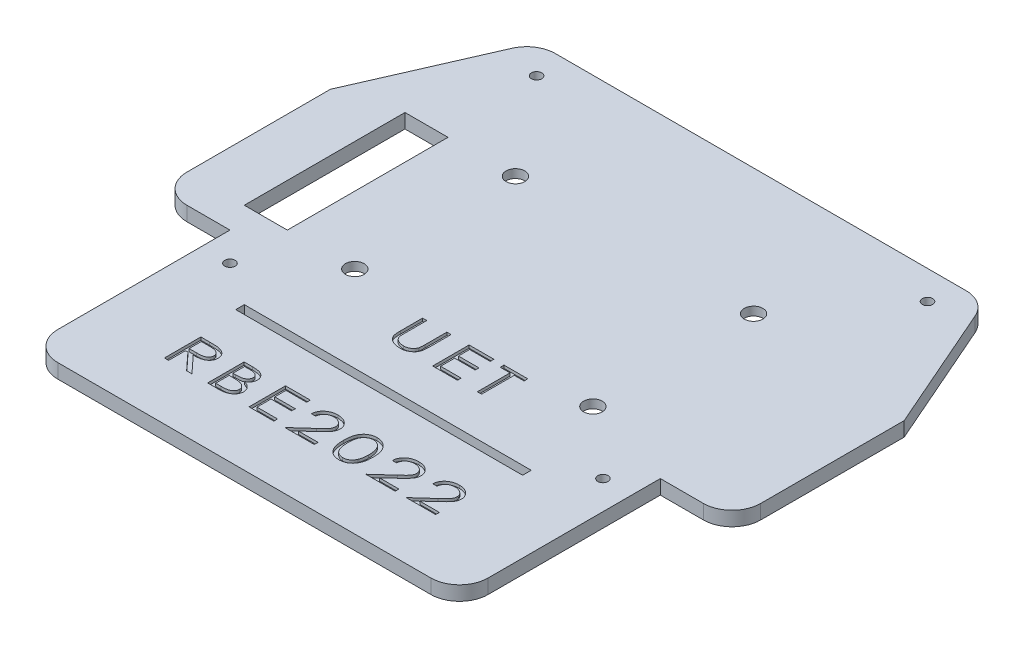
from build123d import *

# Parameters (mm, degrees)
SKETCH1_R           = 1.8
BOSS_EXTRUDE1_DEPTH = 5
SKETCH8_W           = 100
SKETCH8_H           = 3
CUT_EXTRUDE5_DEPTH  = 10
SKETCH9_R           = 1.8
SKETCH9_R_2         = 3.25
SKETCH9_W           = 15
SKETCH9_H           = 56
CUT_EXTRUDE6_DEPTH  = 10
FILLET1_R           = 10
CUT_EXTRUDE7_DEPTH  = 1
SKETCH14_R          = 7.5
CUT_EXTRUDE8_DEPTH  = 2


with BuildPart() as part:
    # Sketch1 → Boss-Extrude1 (new body)
    with BuildSketch(Plane(origin=(0, 0, 0), x_dir=(1, 0, 0), z_dir=(0, 1, 0))):
        with BuildLine():
            Line((-100, -40), (-100, 10))
            Line((-100, 10), (-78.125, 60))
            Line((-78.125, 60), (78.125, 60))
            Line((78.125, 60), (100, 10))
            Line((100, 10), (100, -40))
            ThreePointArc((100, -40), (97.071067812, -47.071067812), (90, -50))
            Line((90, -50), (75, -50))
            Line((75, -50), (75, -60))
            Line((75, -60), (75, -110))
            ThreePointArc((75, -110), (72.071067812, -117.071067812), (65, -120))
            Line((65, -120), (-65, -120))
            ThreePointArc((-65, -120), (-72.071067812, -117.071067812), (-75, -110))
            Line((-75, -110), (-75, -60))
            Line((-75, -60), (-75, -50))
            Line((-75, -50), (-90, -50))
            ThreePointArc((-90, -50), (-97.071067812, -47.071067812), (-100, -40))
        make_face()
        with Locations((-65, -60)):
            Circle(SKETCH1_R, mode=Mode.SUBTRACT)
        with Locations((65, -60)):
            Circle(SKETCH1_R, mode=Mode.SUBTRACT)
    extrude(amount=BOSS_EXTRUDE1_DEPTH)

    # Sketch8 → Cut-Extrude5 (cut)
    with BuildSketch(Plane(origin=(0, 5, 0), x_dir=(1, 0, 0), z_dir=(0, 1, 0))):
        with Locations((0, -71.5)):
            Rectangle(SKETCH8_W, SKETCH8_H)
    extrude(amount=-CUT_EXTRUDE5_DEPTH, mode=Mode.SUBTRACT)

    # Sketch9 → Cut-Extrude6 (cut)
    with BuildSketch(Plane(origin=(0, 5, 0), x_dir=(1, 0, 0), z_dir=(0, 1, 0))):
        with Locations((-68.125, 50)):
            Circle(SKETCH9_R)
        with Locations((68.125, 50)):
            Circle(SKETCH9_R)
        with Locations((41.5, 16)):
            Circle(SKETCH9_R_2)
        with Locations((41.5, -40)):
            Circle(SKETCH9_R_2)
        with Locations((-41.5, 16)):
            Circle(SKETCH9_R_2)
        with Locations((-41.5, -40)):
            Circle(SKETCH9_R_2)
        with Locations((-72.5, -12)):
            Rectangle(SKETCH9_W, SKETCH9_H)
    extrude(amount=-CUT_EXTRUDE6_DEPTH, mode=Mode.SUBTRACT)

    # Fillet1
    fillet1_edges = [part.edges().sort_by_distance(p)[0] for p in [
        (-78.125, 2.5, -60),
        (78.125, 2.5, -60),
    ]]
    fillet(fillet1_edges, radius=FILLET1_R)

    # Sketch13 → Cut-Extrude7 (cut)
    with BuildSketch(Plane(origin=(0, 5, 0), x_dir=(1, 0, 0), z_dir=(0, 1, 0))):
        with BuildLine():
            Line((-14.866348897, -42.992649035), (-13.400964282, -42.992649035))
            Line((-13.400964282, -42.992649035), (-13.400964282, -50.601963939))
            add(Edge.make_bspline(
                [(-13.400964282, -50.601963939), (-13.401628876, -50.709670287), (-13.402890127, -50.9140728), (-13.39446539, -51.204870564), (-13.395620063, -51.463651931), (-13.3851295, -51.690784621), (-13.38113342, -51.886169585), (-13.364699496, -52.049392601), (-13.358810885, -52.181594805), (-13.345597702, -52.258222206), (-13.339906589, -52.29122676)],
                knots=[0, 0, 0, 0, 0.000323097, 0.000613166, 0.000872673, 0.001099224, 0.001295266, 0.001458583, 0.001591265, 0.001691651, 0.001691651, 0.001691651, 0.001691651], degree=3))
            add(Edge.make_bspline(
                [(-13.339906589, -52.29122676), (-13.317284874, -52.410620134), (-13.27312858, -52.643669173), (-13.161183919, -52.974015294), (-13.00876587, -53.273245239), (-12.819053989, -53.546055154), (-12.577198554, -53.788987466), (-12.287320921, -54.012120378), (-11.938597211, -54.208583447), (-11.547195628, -54.385495602), (-11.126186031, -54.530248857), (-10.695723867, -54.637800717), (-10.262824133, -54.704485374), (-9.973483461, -54.711983868), (-9.829089282, -54.715725958)],
                knots=[0, 0, 0, 0, 0.000364255, 0.000711006, 0.001042097, 0.001368899, 0.001703519, 0.002066332, 0.002462987, 0.00290135, 0.003353508, 0.003796535, 0.004231161, 0.004664132, 0.004664132, 0.004664132, 0.004664132], degree=3))
            add(Edge.make_bspline(
                [(-9.829089282, -54.715725958), (-9.705154963, -54.711815781), (-9.458066087, -54.70402003), (-9.09120799, -54.656292888), (-8.733668776, -54.569845422), (-8.385526518, -54.458256027), (-8.058256763, -54.309871321), (-7.751944998, -54.141528398), (-7.479227411, -53.939564662), (-7.230052014, -53.719140631), (-7.011514221, -53.469933571), (-6.826856056, -53.194810511), (-6.67054301, -52.895413871), (-6.59395696, -52.682355156), (-6.554870532, -52.573618586)],
                knots=[0, 0, 0, 0, 0.000371861, 0.000741382, 0.001107313, 0.001474171, 0.001836324, 0.002183755, 0.002520621, 0.002852112, 0.003180229, 0.003511866, 0.003844119, 0.00419043, 0.00419043, 0.00419043, 0.00419043], degree=3))
            add(Edge.make_bspline(
                [(-6.554870532, -52.573618586), (-6.542477438, -52.528804962), (-6.514876532, -52.428999639), (-6.482076366, -52.260860454), (-6.459617766, -52.060781103), (-6.43448333, -51.830372758), (-6.422043294, -51.567910285), (-6.40820902, -51.273722001), (-6.401078027, -50.947990183), (-6.400161143, -50.720689156), (-6.39968223, -50.601963939)],
                knots=[0, 0, 0, 0, 0.000139461, 0.000310595, 0.000513181, 0.000743289, 0.001005773, 0.001301159, 0.001626889, 0.001983068, 0.001983068, 0.001983068, 0.001983068], degree=3))
            Line((-6.39968223, -50.601963939), (-6.39968223, -42.992649035))
            Line((-6.39968223, -42.992649035), (-4.934297615, -42.992649035))
            Line((-4.934297615, -42.992649035), (-4.934297615, -50.663021631))
            add(Edge.make_bspline(
                [(-4.934297615, -50.663021631), (-4.934720257, -50.801284644), (-4.935545304, -51.071189848), (-4.958106139, -51.466447106), (-4.986869456, -51.841670027), (-5.029896975, -52.196558091), (-5.086595167, -52.529834856), (-5.150919413, -52.844817462), (-5.233082128, -53.138103451), (-5.32406431, -53.414540953), (-5.434488183, -53.675907157), (-5.570363396, -53.926035336), (-5.730732685, -54.167597144), (-5.916522619, -54.400504113), (-6.123327838, -54.627521172), (-6.361055907, -54.840119016), (-6.617098072, -55.050118088), (-6.898082999, -55.247258135), (-7.19953783, -55.427466125), (-7.518631399, -55.585409455), (-7.851807462, -55.720278429), (-8.201122296, -55.83129104), (-8.566663088, -55.913033453), (-8.947093682, -55.975127375), (-9.34249932, -56.010529653), (-9.611079473, -56.015673769), (-9.747679025, -56.018290061)],
                knots=[0, 0, 0, 0, 0.000414715, 0.000809571, 0.001187329, 0.001543589, 0.00188153, 0.002201365, 0.0025075, 0.00279471, 0.003073979, 0.003357423, 0.003647425, 0.003942636, 0.00425051, 0.004567449, 0.004898422, 0.005243564, 0.005596099, 0.005951076, 0.006310592, 0.006673468, 0.007049311, 0.007433263, 0.0078292, 0.008238992, 0.008238992, 0.008238992, 0.008238992], degree=3))
            add(Edge.make_bspline(
                [(-9.747679025, -56.018290061), (-9.896126131, -56.015408889), (-10.188295587, -56.009738248), (-10.618469226, -55.978083079), (-11.031641891, -55.917634584), (-11.430164355, -55.841099426), (-11.810960251, -55.73520377), (-12.177632908, -55.61186196), (-12.525278509, -55.46067403), (-12.856580577, -55.290998862), (-13.16546653, -55.101462223), (-13.449398054, -54.894478386), (-13.707601038, -54.67276988), (-13.939112651, -54.436183499), (-14.145841939, -54.185680679), (-14.319889874, -53.917008532), (-14.473136812, -53.636321099), (-14.551989745, -53.438652141), (-14.591589282, -53.339383811)],
                knots=[0, 0, 0, 0, 0.000445394, 0.000876612, 0.001292885, 0.00169752, 0.002093129, 0.002477696, 0.002857181, 0.00322925, 0.003593586, 0.003943171, 0.004282306, 0.004613329, 0.004935171, 0.005254814, 0.005572375, 0.005892736, 0.005892736, 0.005892736, 0.005892736], degree=3))
            add(Edge.make_bspline(
                [(-14.591589282, -53.339383811), (-14.613873956, -53.271847611), (-14.662085528, -53.125737047), (-14.715383729, -52.882744287), (-14.763996159, -52.60361188), (-14.80040216, -52.286662126), (-14.831430285, -51.933820216), (-14.850245701, -51.543431221), (-14.863255994, -51.115954405), (-14.865289097, -50.818221463), (-14.866348897, -50.663021631)],
                knots=[0, 0, 0, 0, 0.000213232, 0.000461315, 0.000745306, 0.001063071, 0.001418012, 0.001807787, 0.00223538, 0.002700972, 0.002700972, 0.002700972, 0.002700972], degree=3))
            Line((-14.866348897, -50.663021631), (-14.866348897, -42.992649035))
        make_face()
        Polygon((1.35057418, -42.992649035), (9.980061359, -42.992649035), (9.980061359, -44.295213138), (2.815958795, -44.295213138), (2.815958795, -48.202905445), (9.980061359, -48.202905445), (9.980061359, -49.505469548), (2.815958795, -49.505469548), (2.815958795, -54.390084933), (9.980061359, -54.390084933), (9.980061359, -55.692649035), (1.35057418, -55.692649035), align=None)
        Polygon((13.496984436, -44.295213138), (13.496984436, -42.992649035), (21.80083059, -42.992649035), (21.80083059, -44.295213138), (18.381599821, -44.295213138), (18.381599821, -55.692649035), (16.916215206, -55.692649035), (16.916215206, -44.295213138), align=None)
        with BuildLine():
            Line((-47.821220692, -87.325982368), (-44.814129346, -87.325982368))
            add(Edge.make_bspline(
                [(-44.814129346, -87.325982368), (-44.613148822, -87.326546908), (-44.227284279, -87.327630773), (-43.674267406, -87.333676757), (-43.17147379, -87.351030176), (-42.720051725, -87.365777026), (-42.319084896, -87.39331751), (-41.969248924, -87.418626255), (-41.669574925, -87.453555079), (-41.488076563, -87.484724814), (-41.405074858, -87.498979163)],
                knots=[0, 0, 0, 0, 0.00060295, 0.00115761, 0.001659024, 0.002112219, 0.002512447, 0.002864643, 0.003164422, 0.003417042, 0.003417042, 0.003417042, 0.003417042], degree=3))
            add(Edge.make_bspline(
                [(-41.405074858, -87.498979163), (-41.295277221, -87.521926355), (-41.078816757, -87.567165579), (-40.766259335, -87.662254546), (-40.469149964, -87.775217328), (-40.186220723, -87.903257973), (-39.920947674, -88.054947147), (-39.670835124, -88.223134419), (-39.435023965, -88.409229887), (-39.21872114, -88.614891625), (-39.017793281, -88.831792946), (-38.848639522, -89.067594534), (-38.701115492, -89.312309954), (-38.584239738, -89.571516369), (-38.492492955, -89.841691015), (-38.426176999, -90.124456124), (-38.384087704, -90.419149044), (-38.379801306, -90.620410542), (-38.377630948, -90.722316503)],
                knots=[0, 0, 0, 0, 0.000336376, 0.000663148, 0.000978777, 0.001289549, 0.001593744, 0.001894332, 0.002193117, 0.002493673, 0.002789048, 0.003078592, 0.003362629, 0.003644975, 0.003929774, 0.004217333, 0.004515239, 0.004820793, 0.004820793, 0.004820793, 0.004820793], degree=3))
            add(Edge.make_bspline(
                [(-38.377630948, -90.722316503), (-38.380011882, -90.808012846), (-38.384713207, -90.977226402), (-38.409249154, -91.227617107), (-38.455644485, -91.469033214), (-38.519145967, -91.703407723), (-38.603697465, -91.928128347), (-38.703278834, -92.147505434), (-38.822745594, -92.357562093), (-38.960284948, -92.559525984), (-39.116507523, -92.748936491), (-39.283819007, -92.931855652), (-39.470658294, -93.098904033), (-39.672227661, -93.255755074), (-39.891954196, -93.396184059), (-40.124009822, -93.530737475), (-40.373827228, -93.649067068), (-40.640183136, -93.757277418), (-40.927863172, -93.850776105), (-41.238030441, -93.93601622), (-41.575205513, -94.002257666), (-41.937285594, -94.061824743), (-42.326166706, -94.106576923), (-42.741111543, -94.139247835), (-43.181479902, -94.15980799), (-43.483557675, -94.162870403), (-43.638768769, -94.164443907)],
                knots=[0, 0, 0, 0, 0.000257153, 0.000507766, 0.000753753, 0.000993841, 0.001235327, 0.001473248, 0.00171591, 0.001959358, 0.002205305, 0.002451923, 0.002702291, 0.002956214, 0.003217301, 0.003483943, 0.003760452, 0.004045797, 0.004345878, 0.004667409, 0.005010179, 0.005376146, 0.005768073, 0.006184073, 0.006624668, 0.007090295, 0.007090295, 0.007090295, 0.007090295], degree=3))
            Line((-43.638768769, -94.164443907), (-38.214810435, -100.025982368))
            Line((-38.214810435, -100.025982368), (-40.07198191, -100.025982368))
            Line((-40.07198191, -100.025982368), (-45.495940243, -94.164443907))
            Line((-45.495940243, -94.164443907), (-46.355836076, -94.164443907))
            Line((-46.355836076, -94.164443907), (-46.355836076, -100.025982368))
            Line((-46.355836076, -100.025982368), (-47.821220692, -100.025982368))
            Line((-47.821220692, -100.025982368), (-47.821220692, -87.325982368))
        make_face()
        with BuildLine():
            Line((-46.355836076, -88.628546471), (-46.355836076, -92.861879804))
            Line((-46.355836076, -92.861879804), (-43.697282391, -92.879688298))
            add(Edge.make_bspline(
                [(-43.697282391, -92.879688298), (-43.57260519, -92.879747875), (-43.331657561, -92.879863012), (-42.98312247, -92.865307602), (-42.659823714, -92.848935678), (-42.361970593, -92.823688851), (-42.088701854, -92.790775214), (-41.840619214, -92.75117285), (-41.617224186, -92.702766325), (-41.357112274, -92.630089572), (-41.065989425, -92.516251129), (-40.751890789, -92.344959171), (-40.480532046, -92.135441034), (-40.252004343, -91.89232154), (-40.072051206, -91.623309834), (-39.939252879, -91.336228593), (-39.856804254, -91.033017235), (-39.847629262, -90.824584211), (-39.843015564, -90.719772433)],
                knots=[0, 0, 0, 0, 0.000373987, 0.000722757, 0.001046344, 0.001345086, 0.001619303, 0.001871923, 0.002098474, 0.002304653, 0.002681657, 0.00303353, 0.003374474, 0.003705653, 0.004030229, 0.004341001, 0.004651388, 0.004965341, 0.004965341, 0.004965341, 0.004965341], degree=3))
            add(Edge.make_bspline(
                [(-39.843015564, -90.719772433), (-39.847642214, -90.617493529), (-39.856845146, -90.414049217), (-39.939492161, -90.11724107), (-40.074102231, -89.83652963), (-40.25899338, -89.57530145), (-40.483016147, -89.337168164), (-40.746574899, -89.134392044), (-41.041833731, -88.96784023), (-41.315611931, -88.86100467), (-41.559870887, -88.795606895), (-41.772720715, -88.749085965), (-42.014078275, -88.71199819), (-42.284119702, -88.682617056), (-42.581782251, -88.656632147), (-42.90844753, -88.639514797), (-43.263026545, -88.629317847), (-43.509013673, -88.628809408), (-43.636224698, -88.628546471)],
                knots=[0, 0, 0, 0, 0.000306347, 0.000609358, 0.000916601, 0.001236315, 0.001565642, 0.001893867, 0.002229935, 0.002579538, 0.002772099, 0.002988166, 0.003232847, 0.003504241, 0.003802982, 0.00412911, 0.004485425, 0.004867044, 0.004867044, 0.004867044, 0.004867044], degree=3))
            Line((-43.636224698, -88.628546471), (-46.355836076, -88.628546471))
        make_face(mode=Mode.SUBTRACT)
        with BuildLine():
            Line((-32.744041205, -87.325982368), (-29.770022775, -87.325982368))
            add(Edge.make_bspline(
                [(-29.770022775, -87.325982368), (-29.62498642, -87.326646769), (-29.342428397, -87.327941146), (-28.931869749, -87.34690843), (-28.547283973, -87.373096479), (-28.189317822, -87.414712247), (-27.857318908, -87.46457365), (-27.550435031, -87.524922095), (-27.26971284, -87.597977555), (-26.935035666, -87.712284205), (-26.554370754, -87.882295616), (-26.141946239, -88.136157662), (-25.784114115, -88.443473896), (-25.480533333, -88.795684406), (-25.236658761, -89.180605749), (-25.056463343, -89.591450823), (-24.949533739, -90.02576471), (-24.93565068, -90.323169316), (-24.928656589, -90.472997593)],
                knots=[0, 0, 0, 0, 0.000435066, 0.00084759, 0.001232762, 0.001591251, 0.001928386, 0.00223972, 0.00252913, 0.002797839, 0.003300002, 0.003776511, 0.004245615, 0.004709201, 0.005166568, 0.005607522, 0.006049942, 0.006499113, 0.006499113, 0.006499113, 0.006499113], degree=3))
            add(Edge.make_bspline(
                [(-24.928656589, -90.472997593), (-24.933331805, -90.613461612), (-24.942554666, -90.89055686), (-25.037358665, -91.294544977), (-25.181460234, -91.680833023), (-25.389811823, -92.04313643), (-25.654459112, -92.378254169), (-25.972576727, -92.683606515), (-26.348908511, -92.953183074), (-26.628651855, -93.099331378), (-26.773107711, -93.174800477)],
                knots=[0, 0, 0, 0, 0.000420703, 0.000829927, 0.001238161, 0.001654061, 0.002078013, 0.002515245, 0.002972761, 0.003461282, 0.003461282, 0.003461282, 0.003461282], degree=3))
            add(Edge.make_bspline(
                [(-26.773107711, -93.174800477), (-26.597613362, -93.230117089), (-26.263179884, -93.335532033), (-25.800054682, -93.521814256), (-25.401205008, -93.725813092), (-25.061447849, -93.945679591), (-24.774881073, -94.1894538), (-24.518071761, -94.445676476), (-24.303309415, -94.733197992), (-24.118462343, -95.039301799), (-23.970705776, -95.363291192), (-23.865666309, -95.704360283), (-23.799819438, -96.05806919), (-23.792565423, -96.299482136), (-23.788913, -96.421034452)],
                knots=[0, 0, 0, 0, 0.000551893, 0.001051724, 0.00149548, 0.001894153, 0.00226256, 0.002622364, 0.002980066, 0.003336091, 0.003693603, 0.004045247, 0.004404546, 0.004768917, 0.004768917, 0.004768917, 0.004768917], degree=3))
            add(Edge.make_bspline(
                [(-23.788913, -96.421034452), (-23.792766171, -96.545081917), (-23.800362449, -96.789633413), (-23.862439454, -97.14897849), (-23.96845806, -97.491407551), (-24.111287625, -97.821364377), (-24.299931687, -98.134911057), (-24.526020905, -98.437437506), (-24.800115902, -98.7185635), (-25.105105648, -98.988925249), (-25.448823581, -99.231126849), (-25.820550199, -99.446921526), (-26.222884363, -99.623144813), (-26.650892265, -99.773092954), (-27.108581945, -99.885811137), (-27.594325351, -99.965812439), (-28.106708895, -100.019212996), (-28.45798997, -100.023689542), (-28.637911397, -100.025982368)],
                knots=[0, 0, 0, 0, 0.000371991, 0.000733357, 0.001089863, 0.001445305, 0.001809187, 0.002185202, 0.002575674, 0.002984921, 0.003406355, 0.003834878, 0.004272199, 0.004721953, 0.005193979, 0.00568416, 0.006198043, 0.006737602, 0.006737602, 0.006737602, 0.006737602], degree=3))
            Line((-28.637911397, -100.025982368), (-32.744041205, -100.025982368))
            Line((-32.744041205, -100.025982368), (-32.744041205, -87.325982368))
        make_face()
        with BuildLine():
            Line((-31.278656589, -88.628546471), (-31.278656589, -92.699059292))
            Line((-31.278656589, -92.699059292), (-30.395864121, -92.699059292))
            add(Edge.make_bspline(
                [(-30.395864121, -92.699059292), (-30.266118449, -92.697608113), (-30.01591775, -92.69480967), (-29.654399163, -92.68681966), (-29.319546302, -92.664278936), (-29.011176005, -92.64172409), (-28.728672049, -92.605221302), (-28.473456639, -92.561878751), (-28.243094564, -92.516128682), (-27.978252764, -92.437300174), (-27.677987035, -92.323207454), (-27.355922368, -92.143887772), (-27.071355744, -91.931751811), (-26.832504579, -91.684090175), (-26.637385832, -91.412339658), (-26.495810751, -91.121107482), (-26.410053412, -90.812778012), (-26.39942467, -90.602433751), (-26.394041205, -90.495894227)],
                knots=[0, 0, 0, 0, 0.000389276, 0.000750677, 0.001084571, 0.001395989, 0.001678094, 0.00193866, 0.002172673, 0.002381999, 0.002767037, 0.003133736, 0.003484311, 0.003827949, 0.004161843, 0.004483856, 0.004794899, 0.005114137, 0.005114137, 0.005114137, 0.005114137], degree=3))
            add(Edge.make_bspline(
                [(-26.394041205, -90.495894227), (-26.396885589, -90.425408037), (-26.402468725, -90.287053327), (-26.434494833, -90.084717858), (-26.494506739, -89.894483975), (-26.575753292, -89.715393273), (-26.681084735, -89.548511788), (-26.810407575, -89.394794152), (-26.961031859, -89.251725999), (-27.136050324, -89.121175665), (-27.336057023, -89.003523113), (-27.563642959, -88.901422359), (-27.819662908, -88.820207564), (-28.101007837, -88.74663918), (-28.411339987, -88.696850697), (-28.747156477, -88.654534541), (-29.110822859, -88.63275495), (-29.362100582, -88.629985881), (-29.492719089, -88.628546471)],
                knots=[0, 0, 0, 0, 0.000211541, 0.000415225, 0.00061237, 0.000808181, 0.001003694, 0.001202392, 0.00140934, 0.001625586, 0.001855961, 0.0021042, 0.002372102, 0.002660873, 0.002975815, 0.00331409, 0.003676073, 0.004067934, 0.004067934, 0.004067934, 0.004067934], degree=3))
            Line((-29.492719089, -88.628546471), (-31.278656589, -88.628546471))
        make_face(mode=Mode.SUBTRACT)
        with BuildLine():
            Line((-31.278656589, -94.001623394), (-31.278656589, -98.723418266))
            Line((-31.278656589, -98.723418266), (-29.401132551, -98.723418266))
            add(Edge.make_bspline(
                [(-29.401132551, -98.723418266), (-29.267140874, -98.72203129), (-29.008449902, -98.719353527), (-28.634298309, -98.710480428), (-28.288000888, -98.690963167), (-27.97017333, -98.658886641), (-27.679383869, -98.625817723), (-27.416478643, -98.579022638), (-27.180751168, -98.527436953), (-26.907112567, -98.446258605), (-26.599529747, -98.322303912), (-26.267959628, -98.131307094), (-25.971391459, -97.907719851), (-25.720876801, -97.644694543), (-25.514733777, -97.360622854), (-25.362944876, -97.059050524), (-25.273178926, -96.74328523), (-25.260590076, -96.528429039), (-25.254297615, -96.421034452)],
                knots=[0, 0, 0, 0, 0.000401995, 0.000776112, 0.001122704, 0.001442175, 0.001734378, 0.002000388, 0.002242944, 0.002457869, 0.002856127, 0.003234476, 0.003602875, 0.00396633, 0.004320038, 0.004652261, 0.004974465, 0.005296468, 0.005296468, 0.005296468, 0.005296468], degree=3))
            add(Edge.make_bspline(
                [(-25.254297615, -96.421034452), (-25.256257797, -96.353936628), (-25.260149123, -96.220734918), (-25.291133495, -96.024339539), (-25.343628248, -95.835047015), (-25.409815899, -95.650502581), (-25.505831076, -95.476868813), (-25.613159409, -95.304617231), (-25.747259701, -95.143099618), (-25.897723611, -94.9873876), (-26.064803981, -94.84032379), (-26.248723668, -94.705064169), (-26.448638875, -94.583244549), (-26.662285042, -94.470766133), (-26.892057411, -94.371719331), (-27.136198297, -94.285834161), (-27.395372861, -94.211299305), (-27.574247368, -94.171933065), (-27.666076461, -94.151723554)],
                knots=[0, 0, 0, 0, 0.000201239, 0.000399497, 0.000594513, 0.000790142, 0.000985887, 0.001188424, 0.001398213, 0.001614115, 0.001837646, 0.002065095, 0.002298096, 0.002539341, 0.00278888, 0.003047976, 0.003315309, 0.003597334, 0.003597334, 0.003597334, 0.003597334], degree=3))
            add(Edge.make_bspline(
                [(-27.666076461, -94.151723554), (-27.738062364, -94.139205281), (-27.893381578, -94.112195431), (-28.145657669, -94.083228059), (-28.433231428, -94.057740578), (-28.757381858, -94.038831378), (-29.11769953, -94.01934799), (-29.514754442, -94.011670721), (-29.948067678, -94.002605662), (-30.249149309, -94.001959897), (-30.406040403, -94.001623394)],
                knots=[0, 0, 0, 0, 0.00021916, 0.000472866, 0.000761469, 0.001085207, 0.001446903, 0.001843909, 0.002276468, 0.002747128, 0.002747128, 0.002747128, 0.002747128], degree=3))
            Line((-30.406040403, -94.001623394), (-31.278656589, -94.001623394))
        make_face(mode=Mode.SUBTRACT)
        Polygon((-18.318143769, -87.325982368), (-9.688656589, -87.325982368), (-9.688656589, -88.628546471), (-16.852759153, -88.628546471), (-16.852759153, -92.536238779), (-9.688656589, -92.536238779), (-9.688656589, -93.838802881), (-16.852759153, -93.838802881), (-16.852759153, -98.723418266), (-9.688656589, -98.723418266), (-9.688656589, -100.025982368), (-18.318143769, -100.025982368), align=None)
        with BuildLine():
            Line((-3.892246333, -91.233674676), (-5.357630948, -91.233674676))
            add(Edge.make_bspline(
                [(-5.357630948, -91.233674676), (-5.348976591, -91.082388777), (-5.331946404, -90.78468589), (-5.251515195, -90.350432525), (-5.128649065, -89.93683372), (-4.963291454, -89.54417044), (-4.754176322, -89.172647247), (-4.507854568, -88.81850146), (-4.211674294, -88.490727001), (-3.879812039, -88.183817705), (-3.51635588, -87.907083316), (-3.129982872, -87.662381873), (-2.720158735, -87.458876872), (-2.29034042, -87.290681094), (-1.839554252, -87.161107452), (-1.369223358, -87.066613419), (-0.877237863, -87.009640674), (-0.541857548, -87.003476831), (-0.371252743, -87.000341343)],
                knots=[0, 0, 0, 0, 0.000454243, 0.000893867, 0.001321278, 0.001746534, 0.00216908, 0.002598214, 0.003037875, 0.003491562, 0.003952565, 0.004406423, 0.004861521, 0.005323092, 0.005789269, 0.006266748, 0.006760933, 0.007272601, 0.007272601, 0.007272601, 0.007272601], degree=3))
            add(Edge.make_bspline(
                [(-0.371252743, -87.000341343), (-0.20320962, -87.003668385), (0.126124652, -87.010188788), (0.607051221, -87.063865635), (1.063429729, -87.154301346), (1.496700425, -87.273418802), (1.904166343, -87.435955662), (2.286366894, -87.632255631), (2.646355166, -87.861379954), (2.973463016, -88.129162739), (3.272194297, -88.416034355), (3.533838659, -88.719632529), (3.75356538, -89.037361954), (3.937293483, -89.365735451), (4.073358831, -89.710713645), (4.177919494, -90.065054952), (4.236483497, -90.434591695), (4.244649435, -90.684811716), (4.248779308, -90.811358971)],
                knots=[0, 0, 0, 0, 0.000504041, 0.000987829, 0.001449345, 0.001898746, 0.002333849, 0.002762802, 0.00318622, 0.003611354, 0.004028767, 0.004427505, 0.004811416, 0.005186025, 0.005553571, 0.005921547, 0.006292537, 0.00667215, 0.00667215, 0.00667215, 0.00667215], degree=3))
            add(Edge.make_bspline(
                [(4.248779308, -90.811358971), (4.246572408, -90.900459109), (4.242169027, -91.078238756), (4.21442609, -91.342968199), (4.164511561, -91.603487659), (4.100513483, -91.861492327), (4.008810875, -92.112366037), (3.905127463, -92.361505743), (3.780299967, -92.605722412), (3.631714606, -92.848678932), (3.457028894, -93.101140779), (3.247823838, -93.369348339), (3.003038537, -93.659232924), (2.722455068, -93.969204642), (2.406657085, -94.300678069), (2.05162682, -94.650508072), (1.663441171, -95.024846979), (1.388923573, -95.277611065), (1.246776103, -95.408494388)],
                knots=[0, 0, 0, 0, 0.000267321, 0.00053338, 0.000797339, 0.001062668, 0.001329807, 0.001597721, 0.001871926, 0.0021516, 0.00245152, 0.002792464, 0.003171624, 0.003589534, 0.004046589, 0.004544896, 0.005084683, 0.00566434, 0.00566434, 0.00566434, 0.00566434], degree=3))
            Line((1.246776103, -95.408494388), (-2.409053224, -98.723418266))
            Line((-2.409053224, -98.723418266), (4.411599821, -98.723418266))
            Line((4.411599821, -98.723418266), (4.411599821, -100.025982368))
            Line((4.411599821, -100.025982368), (-5.846092487, -100.025982368))
            Line((-5.846092487, -100.025982368), (-0.045611717, -94.769932689))
            add(Edge.make_bspline(
                [(-0.045611717, -94.769932689), (0.095427774, -94.644727586), (0.366195784, -94.404358478), (0.750695846, -94.054454814), (1.094097719, -93.72691839), (1.403620628, -93.429138775), (1.669182547, -93.150999225), (1.900801084, -92.902177837), (2.091478594, -92.676078741), (2.293901699, -92.413207741), (2.488876053, -92.091247625), (2.659894396, -91.697594169), (2.764518256, -91.290786946), (2.777092862, -91.015477566), (2.783394693, -90.877504804)],
                knots=[0, 0, 0, 0, 0.000565791, 0.001086208, 0.001559494, 0.001989472, 0.00237451, 0.002713015, 0.003009112, 0.003261488, 0.003707833, 0.004134085, 0.004545643, 0.004959107, 0.004959107, 0.004959107, 0.004959107], degree=3))
            add(Edge.make_bspline(
                [(2.783394693, -90.877504804), (2.780303882, -90.790839931), (2.774204321, -90.619811116), (2.730408603, -90.368238348), (2.655109275, -90.127121721), (2.552948048, -89.893518964), (2.420311656, -89.669908499), (2.257471176, -89.456275794), (2.065052732, -89.25341001), (1.848765567, -89.05814784), (1.608640305, -88.883449682), (1.355994905, -88.725273273), (1.087281885, -88.596437448), (0.806492095, -88.489228398), (0.513107427, -88.404431464), (0.205513284, -88.346930056), (-0.114276993, -88.310532107), (-0.332144642, -88.305469482), (-0.442486717, -88.302905445)],
                knots=[0, 0, 0, 0, 0.000259944, 0.000512986, 0.000763251, 0.00101614, 0.001276183, 0.001541279, 0.001820259, 0.002113931, 0.002414142, 0.002709977, 0.003006947, 0.0033065, 0.003610876, 0.003921721, 0.004244247, 0.00457522, 0.00457522, 0.00457522, 0.00457522], degree=3))
            add(Edge.make_bspline(
                [(-0.442486717, -88.302905445), (-0.5587438, -88.305542136), (-0.787568315, -88.310731835), (-1.123000609, -88.345795432), (-1.443399049, -88.40791686), (-1.748403154, -88.490783958), (-2.038899409, -88.598563243), (-2.314469933, -88.730669172), (-2.574376839, -88.889487148), (-2.818305416, -89.069486855), (-3.042885693, -89.270052065), (-3.243037558, -89.491806801), (-3.413007249, -89.736261744), (-3.562469524, -89.996729341), (-3.684622704, -90.278459873), (-3.780523523, -90.579452732), (-3.853219802, -90.899485107), (-3.879036876, -91.120560273), (-3.892246333, -91.233674676)],
                knots=[0, 0, 0, 0, 0.00034877, 0.000686471, 0.001010288, 0.00132691, 0.001633605, 0.001938554, 0.002242227, 0.002545996, 0.002846853, 0.003144117, 0.003439865, 0.003738379, 0.00404371, 0.004359092, 0.004684982, 0.005026428, 0.005026428, 0.005026428, 0.005026428], degree=3))
        make_face()
        with BuildLine():
            add(Edge.make_bspline(
                [(8.254163924, -93.68107051), (8.255890875, -93.477494038), (8.259246102, -93.081973001), (8.291642755, -92.505925214), (8.336611395, -91.964748668), (8.409410606, -91.459979025), (8.49659306, -90.9907007), (8.60566026, -90.557171405), (8.734428978, -90.158803648), (8.885830325, -89.794579937), (9.056012938, -89.459446203), (9.237786327, -89.145013964), (9.44103051, -88.853662879), (9.658404075, -88.581465605), (9.894148118, -88.33159227), (10.14312348, -88.100484609), (10.412743509, -87.895352358), (10.693604295, -87.706186801), (10.989933714, -87.541746425), (11.294580594, -87.396267255), (11.60833501, -87.273757798), (11.930844811, -87.174654332), (12.261216652, -87.095247656), (12.600461858, -87.039756182), (12.94810442, -87.00542549), (13.182796145, -87.002050037), (13.301599821, -87.000341343)],
                knots=[0, 0, 0, 0, 0.000610662, 0.001186432, 0.00173047, 0.002239208, 0.00271571, 0.003161823, 0.003579369, 0.003970569, 0.00434375, 0.00470634, 0.005059197, 0.005408439, 0.005750406, 0.006088911, 0.006426286, 0.006765679, 0.007103963, 0.007441942, 0.007777846, 0.008113403, 0.008453405, 0.008796365, 0.009143935, 0.009500251, 0.009500251, 0.009500251, 0.009500251], degree=3))
            add(Edge.make_bspline(
                [(13.301599821, -87.000341343), (13.422098426, -87.002050796), (13.660173124, -87.005428244), (14.012890866, -87.039759631), (14.357214533, -87.095240103), (14.692654454, -87.174668382), (15.020280775, -87.273682094), (15.338964581, -87.396440495), (15.649639907, -87.541104448), (15.949239079, -87.709470327), (16.238991225, -87.897737107), (16.5124943, -88.111090221), (16.770146638, -88.34665982), (17.014193974, -88.601979046), (17.239126173, -88.882614908), (17.45156739, -89.183741811), (17.647264921, -89.507952182), (17.828559686, -89.854898238), (17.993040995, -90.227795397), (18.132294401, -90.631309307), (18.248392562, -91.065232145), (18.344418607, -91.529087512), (18.421307577, -92.023998458), (18.472400065, -92.549804191), (18.507208147, -93.105641055), (18.510280271, -93.485967768), (18.511856231, -93.68107051)],
                knots=[0, 0, 0, 0, 0.000361401, 0.000714037, 0.001062018, 0.001406971, 0.001747392, 0.002088041, 0.002430623, 0.00277459, 0.003118228, 0.003466311, 0.003813881, 0.004164788, 0.004524763, 0.004891788, 0.005269632, 0.005659938, 0.006065491, 0.006491112, 0.006939158, 0.007412163, 0.007911579, 0.008440905, 0.008996497, 0.009581722, 0.009581722, 0.009581722, 0.009581722], degree=3))
            add(Edge.make_bspline(
                [(18.511856231, -93.68107051), (18.510263141, -93.875323306), (18.507157964, -94.253951609), (18.472597565, -94.807276896), (18.420657789, -95.330309473), (18.346792927, -95.822752084), (18.254369825, -96.284614163), (18.136088921, -96.71573356), (18.001432143, -97.118417039), (17.838628156, -97.48935753), (17.659987602, -97.833794704), (17.466319988, -98.156542203), (17.254502178, -98.4567551), (17.02848839, -98.737176223), (16.786275488, -98.996018445), (16.525231351, -99.229838527), (16.250677794, -99.444511232), (15.960237339, -99.63547894), (15.656965906, -99.801740223), (15.346801576, -99.951971079), (15.024711469, -100.07218458), (14.696466041, -100.175176114), (14.359714411, -100.254199679), (14.014457554, -100.309042854), (13.661170983, -100.347280653), (13.422122334, -100.350167777), (13.301599821, -100.351623394)],
                knots=[0, 0, 0, 0, 0.000582681, 0.001135734, 0.001662529, 0.002159046, 0.002629046, 0.003074636, 0.003499427, 0.003901632, 0.004288506, 0.004662856, 0.005029882, 0.005389857, 0.005742612, 0.006092068, 0.00644015, 0.006787311, 0.007133501, 0.007477167, 0.007820192, 0.008163793, 0.008508746, 0.008856727, 0.009212141, 0.009573543, 0.009573543, 0.009573543, 0.009573543], degree=3))
            add(Edge.make_bspline(
                [(13.301599821, -100.351623394), (13.182797864, -100.349905277), (12.948109536, -100.346511209), (12.600442089, -100.312316903), (12.262296386, -100.256484171), (11.932798572, -100.179333725), (11.611016839, -100.084523761), (11.300328532, -99.960065365), (10.997496606, -99.818113723), (10.70387541, -99.655863153), (10.424325747, -99.468874937), (10.15616876, -99.263885823), (9.905729998, -99.034073241), (9.675688982, -98.779842215), (9.454262441, -98.510891752), (9.253637441, -98.216140493), (9.06851872, -97.900349214), (8.896012612, -97.562491635), (8.742232476, -97.195738885), (8.609888559, -96.795280275), (8.50305049, -96.359103625), (8.41094227, -95.890648178), (8.340265382, -95.387012781), (8.290578741, -94.848771254), (8.259582009, -94.275899383), (8.256002689, -93.882940897), (8.254163924, -93.68107051)],
                knots=[0, 0, 0, 0, 0.000356315, 0.000703886, 0.001046845, 0.001383788, 0.001718602, 0.002052137, 0.002386728, 0.002721551, 0.003057417, 0.003394792, 0.003733297, 0.004075396, 0.004422659, 0.00477761, 0.005143682, 0.005520282, 0.005914809, 0.006335567, 0.006784146, 0.007261131, 0.00776735, 0.008309087, 0.008882317, 0.009487891, 0.009487891, 0.009487891, 0.009487891], degree=3))
        make_face()
        with BuildLine():
            add(Edge.make_bspline(
                [(9.719548539, -93.675982368), (9.721184553, -93.845603109), (9.72435964, -94.174793689), (9.743906015, -94.653441495), (9.77971114, -95.099699517), (9.826608112, -95.514209568), (9.890824707, -95.896019702), (9.96509955, -96.247487832), (10.05677001, -96.566051767), (10.161583933, -96.855404892), (10.282531723, -97.119029451), (10.415607372, -97.364316241), (10.559448978, -97.594743077), (10.721487515, -97.8051194), (10.89200149, -98.003291397), (11.077725345, -98.184641283), (11.279716149, -98.346333686), (11.55928701, -98.542500821), (11.927685713, -98.744302502), (12.38938631, -98.918374784), (12.863966556, -99.028518377), (13.185684342, -99.042188246), (13.34739309, -99.049059292)],
                knots=[0, 0, 0, 0, 0.000508871, 0.000987589, 0.00143676, 0.001851725, 0.002238599, 0.002597881, 0.002928815, 0.003232243, 0.003520274, 0.003798033, 0.004069057, 0.004334153, 0.004593823, 0.004852894, 0.005111552, 0.005369157, 0.005876959, 0.00636648, 0.006846069, 0.007330753, 0.007330753, 0.007330753, 0.007330753], degree=3))
            add(Edge.make_bspline(
                [(13.34739309, -99.049059292), (13.510002806, -99.04339634), (13.832734109, -99.032157087), (14.305423648, -98.920291367), (14.764161444, -98.753269859), (15.12624768, -98.553302314), (15.401937443, -98.363223471), (15.597713486, -98.200628407), (15.780064667, -98.02118133), (15.947757007, -97.822774042), (16.108201603, -97.612116853), (16.248327932, -97.379290404), (16.380122743, -97.132001524), (16.454160776, -96.957602582), (16.491864244, -96.868790862)],
                knots=[0, 0, 0, 0, 0.000487042, 0.000966631, 0.001449603, 0.001948266, 0.00220233, 0.002453472, 0.002710725, 0.002968732, 0.003232298, 0.003504133, 0.003782938, 0.004072247, 0.004072247, 0.004072247, 0.004072247], degree=3))
            add(Edge.make_bspline(
                [(16.491864244, -96.868790862), (16.536579767, -96.755681372), (16.627063188, -96.526800371), (16.737460183, -96.168303268), (16.83439385, -95.795009767), (16.914075576, -95.404573018), (16.970868872, -94.996493437), (17.013680118, -94.571334892), (17.043627231, -94.129251848), (17.045513414, -93.828677432), (17.046471616, -93.675982368)],
                knots=[0, 0, 0, 0, 0.000364762, 0.000738108, 0.001124379, 0.001521531, 0.001932767, 0.002359822, 0.002803374, 0.003261371, 0.003261371, 0.003261371, 0.003261371], degree=3))
            add(Edge.make_bspline(
                [(17.046471616, -93.675982368), (17.045059493, -93.523310182), (17.042296351, -93.224571945), (17.019205474, -92.787485998), (16.981113395, -92.37164791), (16.929229561, -91.976467054), (16.856636961, -91.603468679), (16.774779529, -91.250035824), (16.671412381, -90.919663286), (16.558343388, -90.60781457), (16.428187327, -90.31880786), (16.287655035, -90.049199152), (16.135488479, -89.799557723), (15.969991375, -89.569566743), (15.791423871, -89.360964676), (15.602779434, -89.170909407), (15.401307239, -89.002945345), (15.120988968, -88.807654778), (14.753775643, -88.609698016), (14.298187974, -88.428890963), (13.82610363, -88.324765432), (13.507302557, -88.310207601), (13.34739309, -88.302905445)],
                knots=[0, 0, 0, 0, 0.000457996, 0.000896175, 0.001312611, 0.001710544, 0.002091246, 0.002452227, 0.002798258, 0.003129075, 0.003446799, 0.003748354, 0.00404069, 0.004323128, 0.004597416, 0.004863657, 0.005125548, 0.005383153, 0.005887502, 0.00637318, 0.006849737, 0.007329346, 0.007329346, 0.007329346, 0.007329346], degree=3))
            add(Edge.make_bspline(
                [(13.34739309, -88.302905445), (13.18492813, -88.310132775), (12.861896313, -88.324502995), (12.384128778, -88.429128166), (11.924846024, -88.60770286), (11.559075676, -88.807797181), (11.281549093, -89.000449157), (11.082564942, -89.162172701), (10.899851821, -89.345337879), (10.726088979, -89.539957319), (10.567388132, -89.753067414), (10.423559857, -89.983138971), (10.286914475, -90.227047952), (10.167528409, -90.492130724), (10.058386948, -90.78016821), (9.968391987, -91.098745653), (9.892442425, -91.449824499), (9.830107358, -91.832910153), (9.779000454, -92.247825565), (9.743969606, -92.695152287), (9.72432593, -93.174621181), (9.72117293, -93.505511404), (9.719548539, -93.675982368)],
                knots=[0, 0, 0, 0, 0.000487221, 0.00096875, 0.001459175, 0.001961292, 0.002215356, 0.002472042, 0.002729295, 0.002990642, 0.003254208, 0.003525233, 0.003804212, 0.004092243, 0.004396554, 0.004727489, 0.005084285, 0.005473669, 0.005891463, 0.006338097, 0.006819357, 0.007330772, 0.007330772, 0.007330772, 0.007330772], degree=3))
        make_face(mode=Mode.SUBTRACT)
        with BuildLine():
            Line((24.308266488, -91.233674676), (22.842881872, -91.233674676))
            add(Edge.make_bspline(
                [(22.842881872, -91.233674676), (22.851536229, -91.082388777), (22.868566416, -90.78468589), (22.948997626, -90.350432525), (23.071863755, -89.93683372), (23.237221367, -89.54417044), (23.446336498, -89.172647247), (23.692658252, -88.81850146), (23.988838527, -88.490727001), (24.320700781, -88.183817705), (24.68415694, -87.907083316), (25.070529948, -87.662381873), (25.480354086, -87.458876872), (25.910172401, -87.290681094), (26.360958568, -87.161107452), (26.831289462, -87.066613419), (27.323274958, -87.009640674), (27.658655272, -87.003476831), (27.829260077, -87.000341343)],
                knots=[0, 0, 0, 0, 0.000454243, 0.000893867, 0.001321278, 0.001746534, 0.00216908, 0.002598214, 0.003037875, 0.003491562, 0.003952565, 0.004406423, 0.004861521, 0.005323092, 0.005789269, 0.006266748, 0.006760933, 0.007272601, 0.007272601, 0.007272601, 0.007272601], degree=3))
            add(Edge.make_bspline(
                [(27.829260077, -87.000341343), (27.9973032, -87.003668385), (28.326637473, -87.010188788), (28.807564042, -87.063865635), (29.263942549, -87.154301346), (29.697213245, -87.273418802), (30.104679163, -87.435955662), (30.486879714, -87.632255631), (30.846867987, -87.861379954), (31.173975836, -88.129162739), (31.472707118, -88.416034355), (31.73435148, -88.719632529), (31.954078201, -89.037361954), (32.137806303, -89.365735451), (32.273871651, -89.710713645), (32.378432315, -90.065054952), (32.436996317, -90.434591695), (32.445162255, -90.684811716), (32.449292129, -90.811358971)],
                knots=[0, 0, 0, 0, 0.000504041, 0.000987829, 0.001449345, 0.001898746, 0.002333849, 0.002762802, 0.00318622, 0.003611354, 0.004028767, 0.004427505, 0.004811416, 0.005186025, 0.005553571, 0.005921547, 0.006292537, 0.00667215, 0.00667215, 0.00667215, 0.00667215], degree=3))
            add(Edge.make_bspline(
                [(32.449292129, -90.811358971), (32.447085229, -90.900459109), (32.442681848, -91.078238756), (32.414938911, -91.342968199), (32.365024381, -91.603487659), (32.301026304, -91.861492327), (32.209323695, -92.112366037), (32.105640283, -92.361505743), (31.980812788, -92.605722412), (31.832227427, -92.848678932), (31.657541714, -93.101140779), (31.448336659, -93.369348339), (31.203551357, -93.659232924), (30.922967888, -93.969204642), (30.607169905, -94.300678069), (30.25213964, -94.650508072), (29.863953991, -95.024846979), (29.589436394, -95.277611065), (29.447288924, -95.408494388)],
                knots=[0, 0, 0, 0, 0.000267321, 0.00053338, 0.000797339, 0.001062668, 0.001329807, 0.001597721, 0.001871926, 0.0021516, 0.00245152, 0.002792464, 0.003171624, 0.003589534, 0.004046589, 0.004544896, 0.005084683, 0.00566434, 0.00566434, 0.00566434, 0.00566434], degree=3))
            Line((29.447288924, -95.408494388), (25.791459597, -98.723418266))
            Line((25.791459597, -98.723418266), (32.612112642, -98.723418266))
            Line((32.612112642, -98.723418266), (32.612112642, -100.025982368))
            Line((32.612112642, -100.025982368), (22.354420334, -100.025982368))
            Line((22.354420334, -100.025982368), (28.154901103, -94.769932689))
            add(Edge.make_bspline(
                [(28.154901103, -94.769932689), (28.295940594, -94.644727586), (28.566708605, -94.404358478), (28.951208666, -94.054454814), (29.29461054, -93.72691839), (29.604133449, -93.429138775), (29.869695367, -93.150999225), (30.101313904, -92.902177837), (30.291991415, -92.676078741), (30.494414519, -92.413207741), (30.689388873, -92.091247625), (30.860407217, -91.697594169), (30.965031076, -91.290786946), (30.977605683, -91.015477566), (30.983907513, -90.877504804)],
                knots=[0, 0, 0, 0, 0.000565791, 0.001086208, 0.001559494, 0.001989472, 0.00237451, 0.002713015, 0.003009112, 0.003261488, 0.003707833, 0.004134085, 0.004545643, 0.004959107, 0.004959107, 0.004959107, 0.004959107], degree=3))
            add(Edge.make_bspline(
                [(30.983907513, -90.877504804), (30.980816702, -90.790839931), (30.974717141, -90.619811116), (30.930921424, -90.368238348), (30.855622095, -90.127121721), (30.753460868, -89.893518964), (30.620824476, -89.669908499), (30.457983996, -89.456275794), (30.265565552, -89.25341001), (30.049278388, -89.05814784), (29.809153125, -88.883449682), (29.556507726, -88.725273273), (29.287794705, -88.596437448), (29.007004915, -88.489228398), (28.713620248, -88.404431464), (28.406026105, -88.346930056), (28.086235828, -88.310532107), (27.868368178, -88.305469482), (27.758026103, -88.302905445)],
                knots=[0, 0, 0, 0, 0.000259944, 0.000512986, 0.000763251, 0.00101614, 0.001276183, 0.001541279, 0.001820259, 0.002113931, 0.002414142, 0.002709977, 0.003006947, 0.0033065, 0.003610876, 0.003921721, 0.004244247, 0.00457522, 0.00457522, 0.00457522, 0.00457522], degree=3))
            add(Edge.make_bspline(
                [(27.758026103, -88.302905445), (27.64176902, -88.305542136), (27.412944505, -88.310731835), (27.077512211, -88.345795432), (26.757113772, -88.40791686), (26.452109666, -88.490783958), (26.161613411, -88.598563243), (25.886042887, -88.730669172), (25.626135982, -88.889487148), (25.382207404, -89.069486855), (25.157627128, -89.270052065), (24.957475262, -89.491806801), (24.787505572, -89.736261744), (24.638043297, -89.996729341), (24.515890117, -90.278459873), (24.419989297, -90.579452732), (24.347293018, -90.899485107), (24.321475945, -91.120560273), (24.308266488, -91.233674676)],
                knots=[0, 0, 0, 0, 0.00034877, 0.000686471, 0.001010288, 0.00132691, 0.001633605, 0.001938554, 0.002242227, 0.002545996, 0.002846853, 0.003144117, 0.003439865, 0.003738379, 0.00404371, 0.004359092, 0.004684982, 0.005026428, 0.005026428, 0.005026428, 0.005026428], degree=3))
        make_face()
        with BuildLine():
            Line((38.408522898, -91.233674676), (36.943138283, -91.233674676))
            add(Edge.make_bspline(
                [(36.943138283, -91.233674676), (36.95179264, -91.082388777), (36.968822826, -90.78468589), (37.049254036, -90.350432525), (37.172120166, -89.93683372), (37.337477777, -89.54417044), (37.546592909, -89.172647247), (37.792914662, -88.81850146), (38.089094937, -88.490727001), (38.420957192, -88.183817705), (38.78441335, -87.907083316), (39.170786358, -87.662381873), (39.580610496, -87.458876872), (40.010428811, -87.290681094), (40.461214978, -87.161107452), (40.931545873, -87.066613419), (41.423531368, -87.009640674), (41.758911683, -87.003476831), (41.929516488, -87.000341343)],
                knots=[0, 0, 0, 0, 0.000454243, 0.000893867, 0.001321278, 0.001746534, 0.00216908, 0.002598214, 0.003037875, 0.003491562, 0.003952565, 0.004406423, 0.004861521, 0.005323092, 0.005789269, 0.006266748, 0.006760933, 0.007272601, 0.007272601, 0.007272601, 0.007272601], degree=3))
            add(Edge.make_bspline(
                [(41.929516488, -87.000341343), (42.097559611, -87.003668385), (42.426893883, -87.010188788), (42.907820452, -87.063865635), (43.36419896, -87.154301346), (43.797469655, -87.273418802), (44.204935573, -87.435955662), (44.587136125, -87.632255631), (44.947124397, -87.861379954), (45.274232246, -88.129162739), (45.572963528, -88.416034355), (45.83460789, -88.719632529), (46.054334611, -89.037361954), (46.238062713, -89.365735451), (46.374128062, -89.710713645), (46.478688725, -90.065054952), (46.537252728, -90.434591695), (46.545418665, -90.684811716), (46.549548539, -90.811358971)],
                knots=[0, 0, 0, 0, 0.000504041, 0.000987829, 0.001449345, 0.001898746, 0.002333849, 0.002762802, 0.00318622, 0.003611354, 0.004028767, 0.004427505, 0.004811416, 0.005186025, 0.005553571, 0.005921547, 0.006292537, 0.00667215, 0.00667215, 0.00667215, 0.00667215], degree=3))
            add(Edge.make_bspline(
                [(46.549548539, -90.811358971), (46.547341639, -90.900459109), (46.542938258, -91.078238756), (46.515195321, -91.342968199), (46.465280791, -91.603487659), (46.401282714, -91.861492327), (46.309580105, -92.112366037), (46.205896694, -92.361505743), (46.081069198, -92.605722412), (45.932483837, -92.848678932), (45.757798125, -93.101140779), (45.548593069, -93.369348339), (45.303807768, -93.659232924), (45.023224299, -93.969204642), (44.707426315, -94.300678069), (44.35239605, -94.650508072), (43.964210402, -95.024846979), (43.689692804, -95.277611065), (43.547545334, -95.408494388)],
                knots=[0, 0, 0, 0, 0.000267321, 0.00053338, 0.000797339, 0.001062668, 0.001329807, 0.001597721, 0.001871926, 0.0021516, 0.00245152, 0.002792464, 0.003171624, 0.003589534, 0.004046589, 0.004544896, 0.005084683, 0.00566434, 0.00566434, 0.00566434, 0.00566434], degree=3))
            Line((43.547545334, -95.408494388), (39.891716007, -98.723418266))
            Line((39.891716007, -98.723418266), (46.712369052, -98.723418266))
            Line((46.712369052, -98.723418266), (46.712369052, -100.025982368))
            Line((46.712369052, -100.025982368), (36.454676744, -100.025982368))
            Line((36.454676744, -100.025982368), (42.255157513, -94.769932689))
            add(Edge.make_bspline(
                [(42.255157513, -94.769932689), (42.396197004, -94.644727586), (42.666965015, -94.404358478), (43.051465076, -94.054454814), (43.39486695, -93.72691839), (43.704389859, -93.429138775), (43.969951777, -93.150999225), (44.201570314, -92.902177837), (44.392247825, -92.676078741), (44.594670929, -92.413207741), (44.789645284, -92.091247625), (44.960663627, -91.697594169), (45.065287487, -91.290786946), (45.077862093, -91.015477566), (45.084163924, -90.877504804)],
                knots=[0, 0, 0, 0, 0.000565791, 0.001086208, 0.001559494, 0.001989472, 0.00237451, 0.002713015, 0.003009112, 0.003261488, 0.003707833, 0.004134085, 0.004545643, 0.004959107, 0.004959107, 0.004959107, 0.004959107], degree=3))
            add(Edge.make_bspline(
                [(45.084163924, -90.877504804), (45.081073113, -90.790839931), (45.074973551, -90.619811116), (45.031177834, -90.368238348), (44.955878506, -90.127121721), (44.853717279, -89.893518964), (44.721080887, -89.669908499), (44.558240407, -89.456275794), (44.365821963, -89.25341001), (44.149534798, -89.05814784), (43.909409535, -88.883449682), (43.656764136, -88.725273273), (43.388051116, -88.596437448), (43.107261326, -88.489228398), (42.813876658, -88.404431464), (42.506282515, -88.346930056), (42.186492238, -88.310532107), (41.968624588, -88.305469482), (41.858282513, -88.302905445)],
                knots=[0, 0, 0, 0, 0.000259944, 0.000512986, 0.000763251, 0.00101614, 0.001276183, 0.001541279, 0.001820259, 0.002113931, 0.002414142, 0.002709977, 0.003006947, 0.0033065, 0.003610876, 0.003921721, 0.004244247, 0.00457522, 0.00457522, 0.00457522, 0.00457522], degree=3))
            add(Edge.make_bspline(
                [(41.858282513, -88.302905445), (41.742025431, -88.305542136), (41.513200915, -88.310731835), (41.177768622, -88.345795432), (40.857370182, -88.40791686), (40.552366076, -88.490783958), (40.261869821, -88.598563243), (39.986299298, -88.730669172), (39.726392392, -88.889487148), (39.482463815, -89.069486855), (39.257883538, -89.270052065), (39.057731673, -89.491806801), (38.887761982, -89.736261744), (38.738299707, -89.996729341), (38.616146527, -90.278459873), (38.520245707, -90.579452732), (38.447549428, -90.899485107), (38.421732355, -91.120560273), (38.408522898, -91.233674676)],
                knots=[0, 0, 0, 0, 0.00034877, 0.000686471, 0.001010288, 0.00132691, 0.001633605, 0.001938554, 0.002242227, 0.002545996, 0.002846853, 0.003144117, 0.003439865, 0.003738379, 0.00404371, 0.004359092, 0.004684982, 0.005026428, 0.005026428, 0.005026428, 0.005026428], degree=3))
        make_face()
    extrude(amount=-CUT_EXTRUDE7_DEPTH, mode=Mode.SUBTRACT)

    # Sketch14 → Cut-Extrude8 (cut)
    with BuildSketch(Plane.XZ):
        with Locations((-41.5, 40)):
            Circle(SKETCH14_R)
        with Locations((41.5, 40)):
            Circle(SKETCH14_R)
        with Locations((41.5, -16)):
            Circle(SKETCH14_R)
        with Locations((-41.5, -16)):
            Circle(SKETCH14_R)
    extrude(amount=-CUT_EXTRUDE8_DEPTH, mode=Mode.SUBTRACT)


solid = part.part
